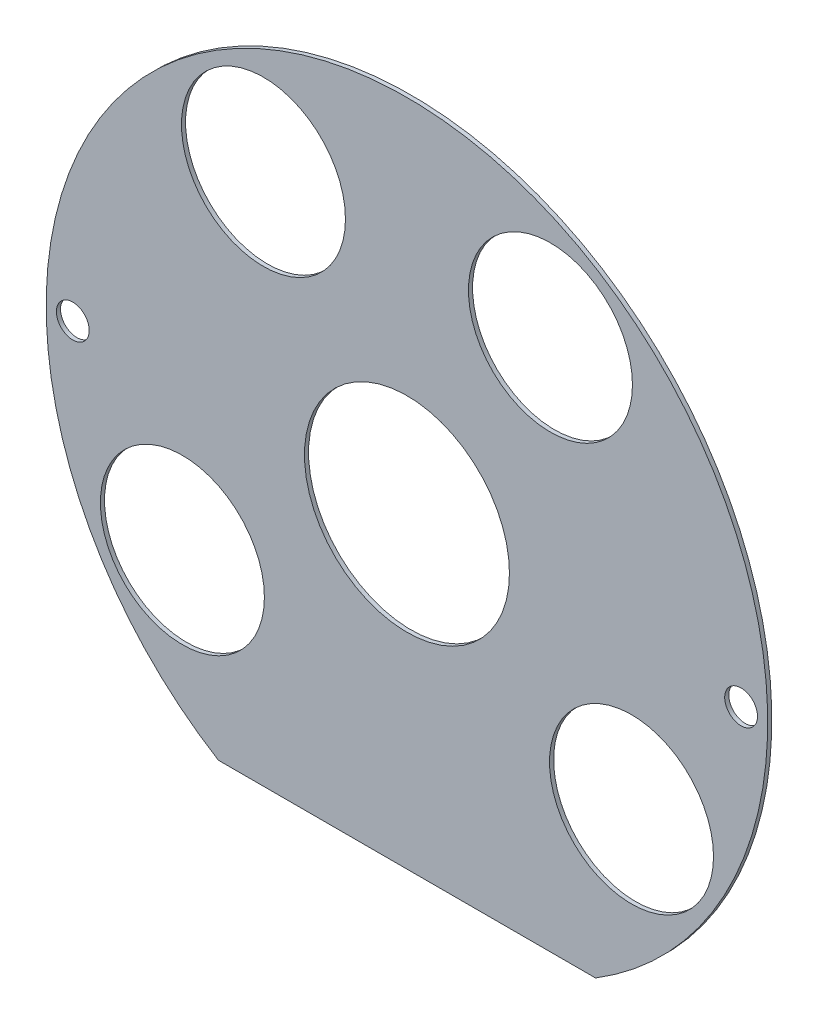
from build123d import *

# Parameters (mm, degrees)
ESBO_O1_R                = 25
ESBO_O1_R_2              = 20
RESSALTO_EXTRUS_O1_DEPTH = 1
ESBO_O2_R                = 4
CORTE_EXTRUS_O1_DEPTH    = 1


with BuildPart() as part:
    # Esboço1 → Ressalto-extrusão1 (new body)
    with BuildSketch(Plane.XY):
        with BuildLine():
            Line((-46, -75.019997334), (46, -75.019997334))
            ThreePointArc((46, -75.019997334), (0, 88), (-46, -75.019997334))
        make_face()
        Circle(ESBO_O1_R, mode=Mode.SUBTRACT)
        with Locations((-35, 54.772)):
            Circle(ESBO_O1_R_2, mode=Mode.SUBTRACT)
        with Locations((35, 54.772)):
            Circle(ESBO_O1_R_2, mode=Mode.SUBTRACT)
        with Locations((-54.772, -35)):
            Circle(ESBO_O1_R_2, mode=Mode.SUBTRACT)
        with Locations((54.772, -35)):
            Circle(ESBO_O1_R_2, mode=Mode.SUBTRACT)
    extrude(amount=RESSALTO_EXTRUS_O1_DEPTH)

    # Esboço2 → Corte-extrusão1 (cut)
    with BuildSketch(Plane.XY.offset(1)):
        with Locations((81.5, 0)):
            Circle(ESBO_O2_R)
        with Locations((-81.5, 0)):
            Circle(ESBO_O2_R)
    extrude(amount=-CORTE_EXTRUS_O1_DEPTH, mode=Mode.SUBTRACT)


solid = part.part
